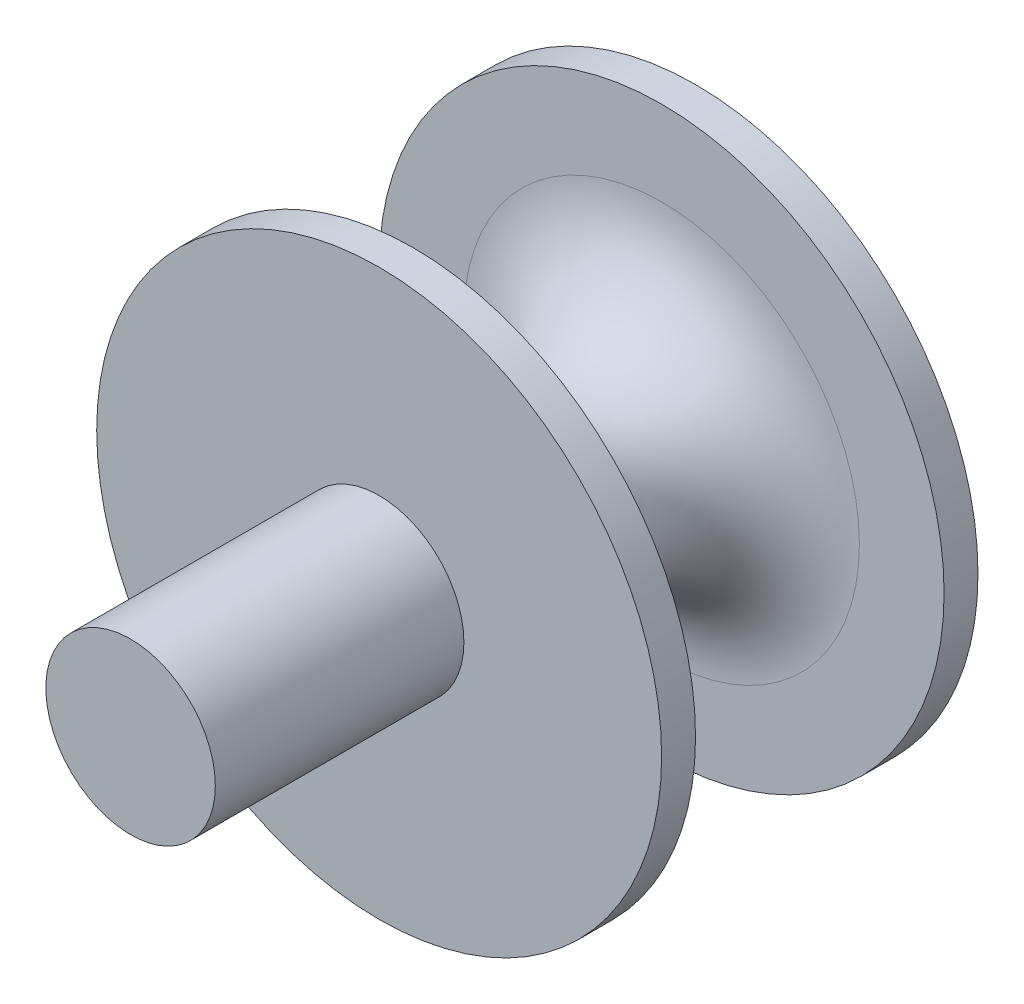
from build123d import *

# Parameters (mm, degrees)
CROQUIS1_R              = 7.5
SALIENTE_EXTRUIR2_DEPTH = 50
CROQUIS4_R              = 25
SALIENTE_EXTRUIR3_DEPTH = 3
SALIENTE_EXTRUIR4_START = 25
CROQUIS5_R              = 25
SALIENTE_EXTRUIR4_DEPTH = 3
REDONDEO2_R             = 10


with BuildPart() as part:
    # Croquis1 → Saliente-Extruir2 (new body)
    with BuildSketch(Plane.XY):
        Circle(CROQUIS1_R)
    extrude(amount=SALIENTE_EXTRUIR2_DEPTH)

    # Croquis4 → Saliente-Extruir3 (add)
    with BuildSketch(Plane.XY):
        Circle(CROQUIS4_R)
    extrude(amount=SALIENTE_EXTRUIR3_DEPTH)

    # Croquis5 → Saliente-Extruir4 (add)
    with BuildSketch(Plane.XY.offset(SALIENTE_EXTRUIR4_START)):
        Circle(CROQUIS5_R)
    extrude(amount=SALIENTE_EXTRUIR4_DEPTH)

    # Redondeo2
    redondeo2_edges = [part.edges().sort_by_distance(p)[0] for p in [
        (-7.5, 0, 25),
        (-7.5, 0, 3),
    ]]
    fillet(redondeo2_edges, radius=REDONDEO2_R)


solid = part.part
